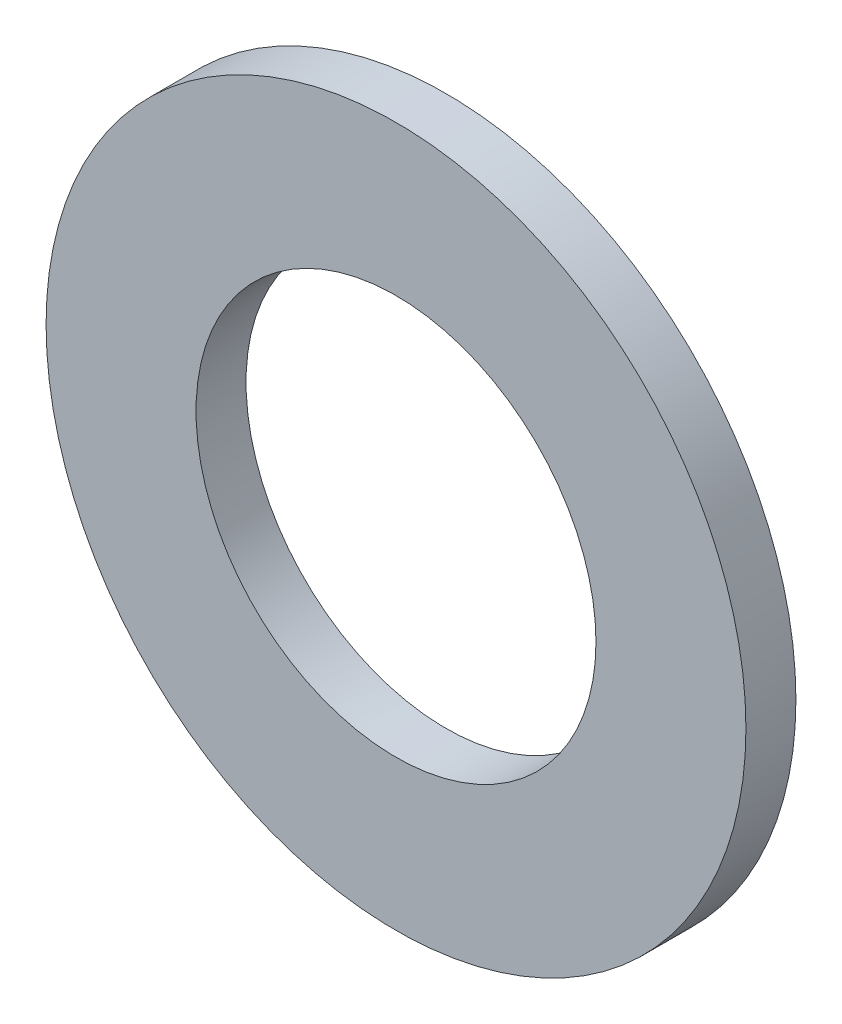
from build123d import *

# Parameters (mm, degrees)
SKETCH1_R           = 7
SKETCH1_R_2         = 4
BOSS_EXTRUDE1_DEPTH = 1


with BuildPart() as part:
    # Sketch1 → Boss-Extrude1 (new body)
    with BuildSketch(Plane.XY):
        Circle(SKETCH1_R)
        Circle(SKETCH1_R_2, mode=Mode.SUBTRACT)
    extrude(amount=BOSS_EXTRUDE1_DEPTH)


solid = part.part
